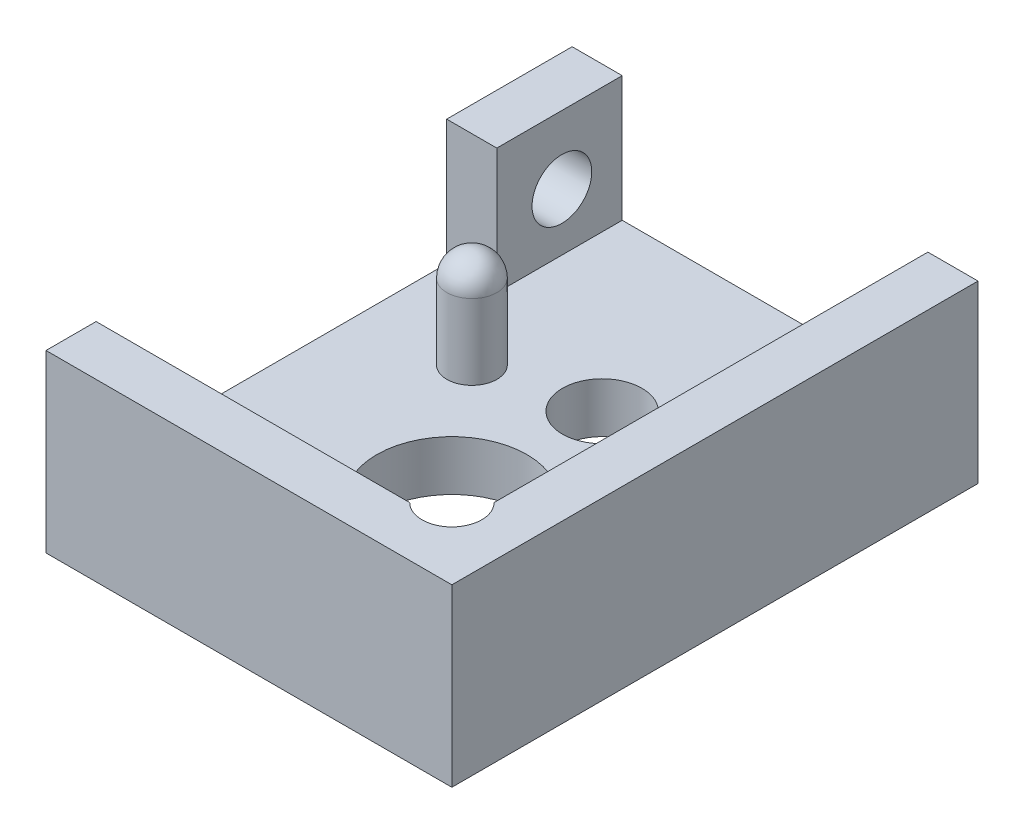
from build123d import *

# Parameters (mm, degrees)
SKETCH1_W                          = 8.1
SKETCH1_H                          = 11.5
BOSS_EXTRUDE1_DEPTH                = 3.5
SKETCH2_W                          = 6.1
SKETCH2_H                          = 9.5
CUT_EXTRUDE1_DEPTH                 = 2.5
SKETCH3_R                          = 1.5
CUT_EXTRUDE2_DEPTH                 = 2
SKETCH6_R                          = 0.5953125
CUT_EXTRUDE5_DEPTH                 = 2.5
SKETCH7_R                          = 0.79375
CUT_EXTRUDE6_DEPTH                 = 2
SKETCH16_W                         = 8.991857398
SKETCH16_H                         = 1
BACK_CUT_EXTRUDE_DEPTH             = 4
SKETCH17_W                         = 1
SKETCH17_H                         = 6.996497869
SIDE_CUT_EXTRUDE_DEPTH             = 3
SKETCH18_R                         = 0.5
PEG_EXTRUDE_DEPTH                  = 2
FILLET1_R                          = 0.5
TAP_DRILL_SLOT_FOR_0_80_TAP2_D     = 1.19126
TAP_DRILL_SLOT_FOR_0_80_TAP2_DEPTH = 1
TAP_DRILL_SLOT_FOR_0_80_TAP2_TIP   = 0.357890611


with BuildPart() as part:
    # Sketch1 → Boss-Extrude1 (new body)
    with BuildSketch(Plane(origin=(0, 0, 0), x_dir=(1, 0, 0), z_dir=(0, 1, 0))):
        Rectangle(SKETCH1_W, SKETCH1_H)
    extrude(amount=BOSS_EXTRUDE1_DEPTH)

    # Sketch2 → Cut-Extrude1 (cut)
    with BuildSketch(Plane(origin=(0, 3.5, 0), x_dir=(1, 0, 0), z_dir=(0, 1, 0))):
        Rectangle(SKETCH2_W, SKETCH2_H)
    extrude(amount=-CUT_EXTRUDE1_DEPTH, mode=Mode.SUBTRACT)

    # Sketch3 → Cut-Extrude2 (cut, through all)
    with BuildSketch(Plane(origin=(0, 1, 0), x_dir=(1, 0, 0), z_dir=(0, 1, 0))):
        with Locations((0.05, -1.75)):
            Circle(SKETCH3_R)
    extrude(amount=-CUT_EXTRUDE2_DEPTH, mode=Mode.SUBTRACT)

    # Sketch6 → Cut-Extrude5 (cut)
    with BuildSketch(Plane(origin=(0, 3.5, 0), x_dir=(1, 0, 0), z_dir=(0, 1, 0))):
        with Locations((2.629050494, -4.329050494)):
            Circle(SKETCH6_R)
    extrude(amount=-CUT_EXTRUDE5_DEPTH, mode=Mode.SUBTRACT)

    # Sketch7 → Cut-Extrude6 (cut, through all)
    with BuildSketch(Plane(origin=(0, 1, 0), x_dir=(1, 0, 0), z_dir=(0, 1, 0))):
        with Locations((0.05, 1.25)):
            Circle(SKETCH7_R)
        with Locations((-1.825, -3.5)):
            Circle(SKETCH7_R)
        with Locations((1.925, -3.5)):
            Circle(SKETCH7_R)
    extrude(amount=-CUT_EXTRUDE6_DEPTH, mode=Mode.SUBTRACT)

    # Sketch16 → Back-cut-extrude (cut)
    with BuildSketch(Plane.XZ):
        with Locations((-0.234538983, -5.25)):
            Rectangle(SKETCH16_W, SKETCH16_H)
    extrude(amount=-BACK_CUT_EXTRUDE_DEPTH, mode=Mode.SUBTRACT)

    # Sketch17 → Side-cut-extrude (cut)
    with BuildSketch(Plane(origin=(0, 1, 0), x_dir=(1, 0, 0), z_dir=(0, 1, 0))):
        with Locations((-3.55, -1.251751065)):
            Rectangle(SKETCH17_W, SKETCH17_H)
    extrude(amount=SIDE_CUT_EXTRUDE_DEPTH, mode=Mode.SUBTRACT)

    # Sketch18 → Peg-Extrude (add)
    with BuildSketch(Plane(origin=(0, 1, 0), x_dir=(1, 0, 0), z_dir=(0, 1, 0))):
        with Locations((-2.05, 0.75)):
            Circle(SKETCH18_R)
    extrude(amount=PEG_EXTRUDE_DEPTH)

    # Fillet1
    fillet1_edges = [part.edges().sort_by_distance(p)[0] for p in [
        (-2.55, 3, -0.75),
    ]]
    fillet(fillet1_edges, radius=FILLET1_R)

    # Tap Drill Slot for #0-80 Tap2
    with Locations(Plane.ZY.offset(4.05)):
        with Locations((-3.545754268, 2.143662575)):
            Hole(TAP_DRILL_SLOT_FOR_0_80_TAP2_D / 2, depth=TAP_DRILL_SLOT_FOR_0_80_TAP2_DEPTH)
            with Locations((0, 0, -(TAP_DRILL_SLOT_FOR_0_80_TAP2_DEPTH + TAP_DRILL_SLOT_FOR_0_80_TAP2_TIP / 2))):  # 118° drill point
                Cone(0, TAP_DRILL_SLOT_FOR_0_80_TAP2_D / 2, TAP_DRILL_SLOT_FOR_0_80_TAP2_TIP, mode=Mode.SUBTRACT)


solid = part.part
